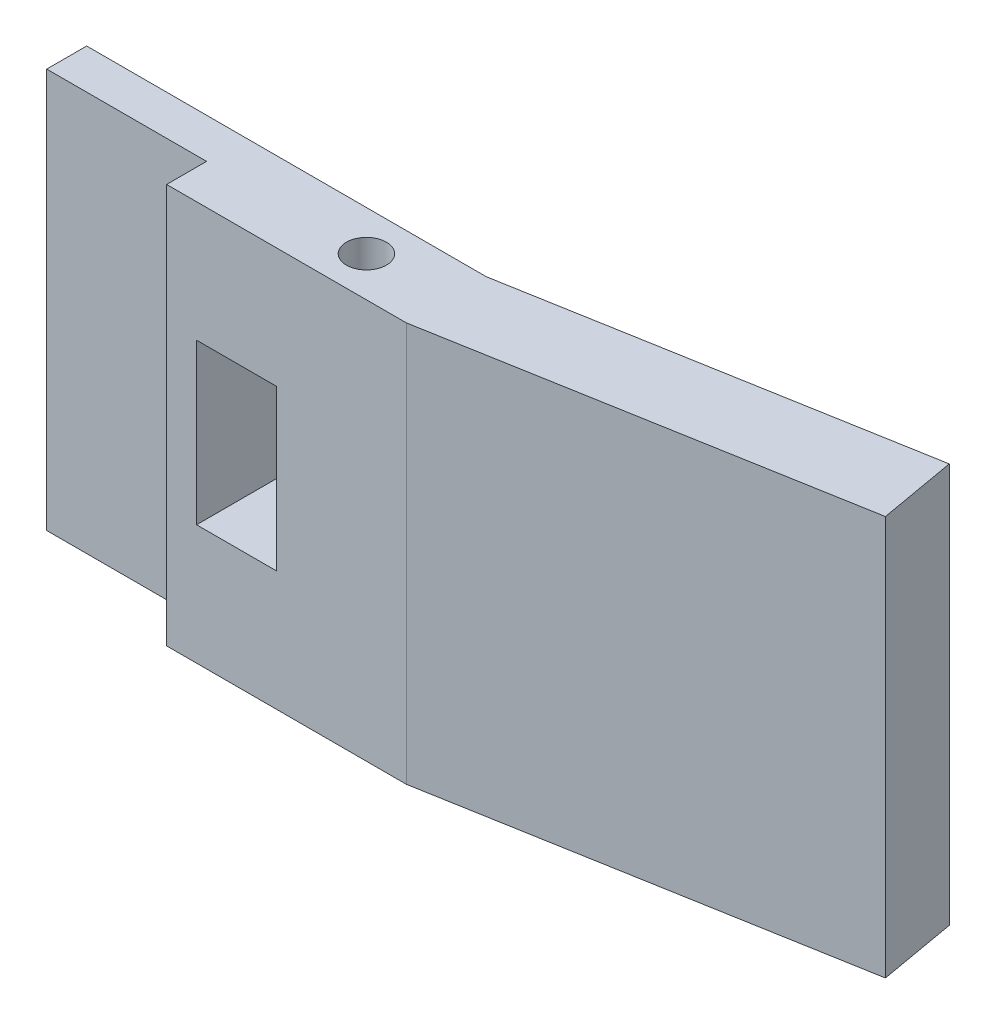
from build123d import *

# Parameters (mm, degrees)
SKETCH1_R           = 1.5875
BOSS_EXTRUDE1_DEPTH = 31.75
SKETCH2_W           = 6.35
SKETCH2_H           = 12.7
CUT_EXTRUDE1_DEPTH  = 12.863329641


with BuildPart() as part:
    # Sketch1 → Boss-Extrude1 (new body)
    with BuildSketch(Plane(origin=(0, 0, 0), x_dir=(1, 0, 0), z_dir=(0, 1, 0))):
        Polygon((12.7, -6.35), (31.75, -6.35), (64.103560113, -0.64519443), (63.017646158, 5.513329641), (31.75, 0), (0, 0), (0, -3.175), (12.7, -3.175), align=None)
        with Locations((25.4, -3.175)):
            Circle(SKETCH1_R, mode=Mode.SUBTRACT)
    extrude(amount=BOSS_EXTRUDE1_DEPTH)

    # Sketch2 → Cut-Extrude1 (cut, through all)
    with BuildSketch(Plane.XY.offset(6.35)):
        with Locations((18.25625, 15.875)):
            Rectangle(SKETCH2_W, SKETCH2_H)
    extrude(amount=-CUT_EXTRUDE1_DEPTH, mode=Mode.SUBTRACT)


solid = part.part
